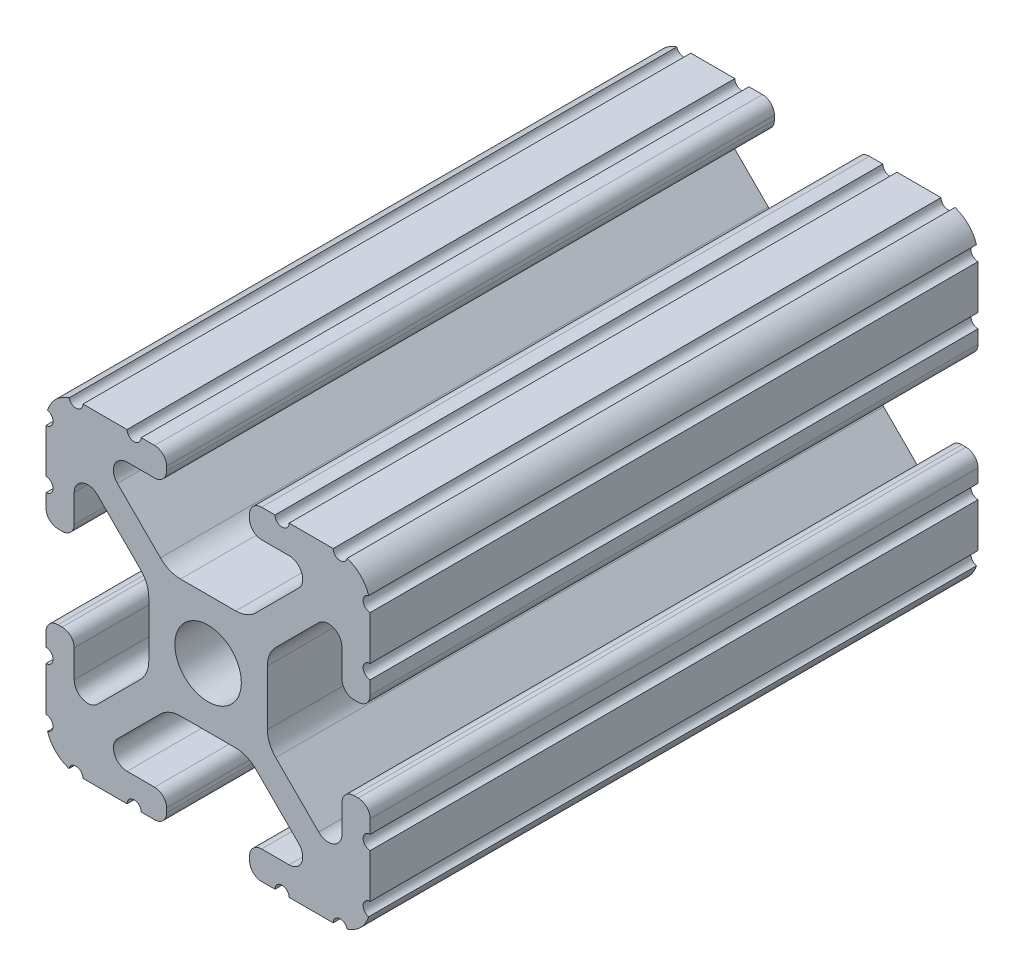
from build123d import *

# Parameters (mm, degrees)
BOSS_EXTRUDE1_DEPTH     = 23.8125
SKETCH5_R               = 0.55245
CUT_EXTRUDE1_DEPTH      = 24.8125
CUT_EXTRUDE1_DEPTH_BACK = 24.8125


with BuildPart() as part:
    # Sketch4 → Boss-Extrude1 (new body, symmetric)
    with BuildSketch(Plane.XY):
        with BuildLine():
            Line((4.190365, -12.7), (10.11729625, -12.7))
            ThreePointArc((10.11729625, -12.7), (11.943543585, -11.943543585), (12.7, -10.11729625))
            Line((12.7, -10.11729625), (12.7, -4.190365))
            ThreePointArc((12.7, -4.190365), (12.42492494, -3.52627506), (11.760835, -3.2512))
            Line((11.760835, -3.2512), (11.429365, -3.2512))
            ThreePointArc((11.429365, -3.2512), (10.76527506, -3.52627506), (10.4902, -4.190365))
            Line((10.4902, -4.190365), (10.4902, -6.348478019))
            ThreePointArc((10.4902, -6.348478019), (9.830707141, -7.335478831), (8.666460301, -7.103895736))
            Line((8.666460301, -7.103895736), (5.299899128, -3.737334563))
            ThreePointArc((5.299899128, -3.737334563), (4.817571085, -3.015479634), (4.6482, -2.16399369))
            Line((4.6482, -2.16399369), (4.6482, 0))
            Line((4.6482, 0), (2.6035, 0))
            ThreePointArc((2.6035, 0), (1.840952505, -1.840952505), (0, -2.6035))
            Line((0, -2.6035), (0, -4.6482))
            Line((0, -4.6482), (2.16399369, -4.6482))
            ThreePointArc((2.16399369, -4.6482), (3.015479634, -4.817571085), (3.737334563, -5.299899128))
            Line((3.737334563, -5.299899128), (7.103895736, -8.666460301))
            ThreePointArc((7.103895736, -8.666460301), (7.335478831, -9.830707141), (6.348478019, -10.4902))
            Line((6.348478019, -10.4902), (4.190365, -10.4902))
            ThreePointArc((4.190365, -10.4902), (3.52627506, -10.76527506), (3.2512, -11.429365))
            Line((3.2512, -11.429365), (3.2512, -11.760835))
            ThreePointArc((3.2512, -11.760835), (3.52627506, -12.42492494), (4.190365, -12.7))
        make_face()
    extrude(amount=BOSS_EXTRUDE1_DEPTH, both=True)

    # Sketch5 → Cut-Extrude1 (cut, two sides)
    with BuildSketch(Plane.XY) as cut_extrude1_sk:
        with Locations((10.356153152, -12.7)):
            Circle(SKETCH5_R)
        with Locations((5.796028019, -12.7)):
            Circle(SKETCH5_R)
        with Locations((12.7, -10.356153152)):
            Circle(SKETCH5_R)
        with Locations((12.7, -5.796028019)):
            Circle(SKETCH5_R)
    extrude(amount=CUT_EXTRUDE1_DEPTH, mode=Mode.SUBTRACT)
    extrude(cut_extrude1_sk.sketch, amount=-CUT_EXTRUDE1_DEPTH_BACK, mode=Mode.SUBTRACT)

    # Mirror1: part across plane


with BuildPart() as part_1:
    add(part.part)
    add(part.part.mirror(Plane(origin=(0, 0, 0), x_dir=(0, 0, 1), z_dir=(1, 0, 0))))

    # Mirror2: part across plane


with BuildPart() as part_2:
    add(part_1.part)
    add(part_1.part.mirror(Plane.ZX))


solid = part_2.part
